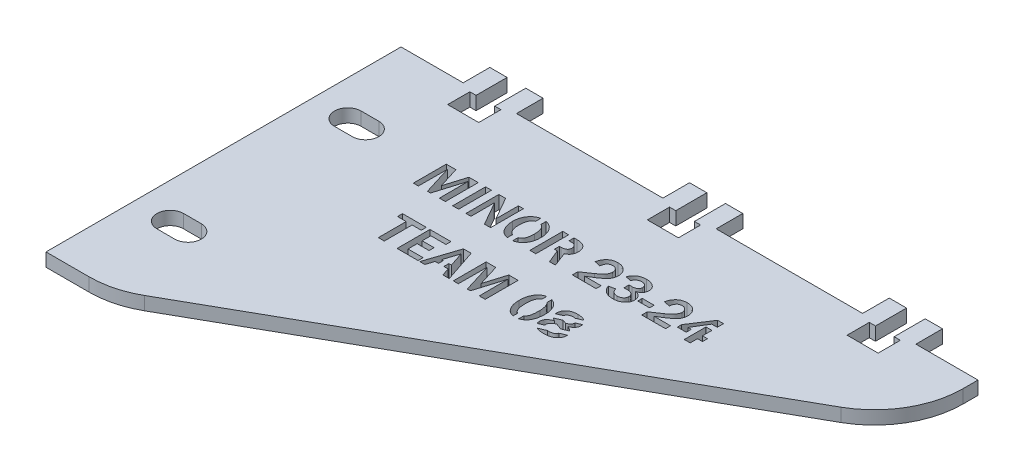
from build123d import *

# Parameters (mm, degrees)
SKETCH1_W               = 12
SKETCH1_H               = 6
BOSS_EXTRUDE1_DEPTH     = 3
CUT_EXTRUDE1_DEPTH      = 10
SKETCH3_W               = 4.2
SKETCH3_H               = 7
CUT_EXTRUDE2_DEPTH      = 10
FILLET1_R               = 20
SKETCH5_W               = 1.33798896
SKETCH5_H               = 7.41040039
SKETCH5_W_2             = 2.675977919
SKETCH5_H_2             = 1.029222276
CUT_EXTRUDE3_DEPTH      = 153.672852859
CUT_EXTRUDE3_DEPTH_BACK = 153.672852859
SKETCH6_W               = 1.2
SKETCH6_H               = 9.253585129
SKETCH6_H_2             = 4.425655788
SKETCH6_H_3             = 1.132144504
SKETCH6_H_4             = 1.586041103
SKETCH6_H_5             = 10.05312392
BOSS_EXTRUDE2_DEPTH     = 3


with BuildPart() as part:
    # Sketch1 → Boss-Extrude1 (new body)
    with BuildSketch(Plane(origin=(0, 0, 0), x_dir=(1, 0, 0), z_dir=(0, 1, 0))):
        Polygon((0, 0), (130, 0), (130, -15), (15, -80), (0, -80), align=None)
        with Locations((110, 3)):
            Rectangle(SKETCH1_W, SKETCH1_H)
        with Locations((65, 3)):
            Rectangle(SKETCH1_W, SKETCH1_H)
        with Locations((20, 3)):
            Rectangle(SKETCH1_W, SKETCH1_H)
    extrude(amount=BOSS_EXTRUDE1_DEPTH)

    # Sketch2 → Cut-Extrude1 (cut)
    with BuildSketch(Plane(origin=(0, 3, 0), x_dir=(1, 0, 0), z_dir=(0, 1, 0))):
        with BuildLine():
            Line((8, -17), (12, -17))
            ThreePointArc((12, -17), (15, -20), (12, -23))
            Line((12, -23), (8, -23))
            ThreePointArc((8, -23), (5, -20), (8, -17))
        make_face()
        with BuildLine():
            Line((8, -57), (12, -57))
            ThreePointArc((12, -57), (15, -60), (12, -63))
            Line((12, -63), (8, -63))
            ThreePointArc((8, -63), (5, -60), (8, -57))
        make_face()
    extrude(amount=-CUT_EXTRUDE1_DEPTH, mode=Mode.SUBTRACT)

    # Sketch3 → Cut-Extrude2 (cut)
    with BuildSketch(Plane(origin=(0, 3, 0), x_dir=(1, 0, 0), z_dir=(0, 1, 0))):
        Polygon((67.1, -1), (62.9, -1), (61.5, -1), (61.5, -6), (68.5, -6), (68.5, -1), align=None)
        with Locations((65, 2.5)):
            Rectangle(SKETCH3_W, SKETCH3_H)
        with Locations((20, 2.5)):
            Rectangle(SKETCH3_W, SKETCH3_H)
        Polygon((22.1, -1), (17.9, -1), (16.5, -1), (16.5, -6), (23.5, -6), (23.5, -1), align=None)
        with Locations((110, 2.5)):
            Rectangle(SKETCH3_W, SKETCH3_H)
        Polygon((112.1, -1), (107.9, -1), (106.5, -1), (106.5, -6), (113.5, -6), (113.5, -1), align=None)
    extrude(amount=-CUT_EXTRUDE2_DEPTH, mode=Mode.SUBTRACT)

    # Fillet1
    fillet1_edges = [part.edges().sort_by_distance(p)[0] for p in [
        (15, 1.5, 80),
        (130, 1.5, 15),
    ]]
    fillet(fillet1_edges, radius=FILLET1_R)

    # Sketch5 → Cut-Extrude3 (cut, two sides)
    with BuildSketch(Plane(origin=(0, 3, 0), x_dir=(1, 0, 0), z_dir=(0, 1, 0))) as cut_extrude3_sk:
        Polygon((35.169841553, -25.187136643), (33.831852594, -25.187136643), (33.806122037, -18.699819982), (31.834518113, -25.187136643), (31.134968597, -25.187136643), (29.123160679, -18.699819982), (29.097430122, -25.187136643), (27.965285618, -25.187136643), (27.965285618, -17.776736253), (30.134693197, -17.776736253), (31.619024699, -22.552970879), (33.071193005, -17.776736253), (35.169841553, -17.776736253), align=None)
        with Locations((37.485591675, -21.481936448)):
            Rectangle(SKETCH5_W, SKETCH5_H)
        with BuildLine():
            Line((45.35914209, -25.187136643), (43.982557295, -25.187136643))
            Line((43.982557295, -25.187136643), (41.282456979, -20.452714171))
            add(Edge.make_bspline(
                [(41.282456979, -20.452714171), (41.270682779, -20.431797346), (41.243481643, -20.383474624), (41.19764017, -20.30322362), (41.142168283, -20.204968249), (41.101838717, -20.134280536), (41.079828844, -20.095702694)],
                knots=[0, 0, 0, 0, 0.701659127, 1.620995457, 2.701657538, 4, 4, 4, 4], degree=3))
            add(Edge.make_bspline(
                [(41.079828844, -20.095702694), (41.057376283, -20.055999473), (41.009034469, -19.970515871), (40.959834914, -19.885522906), (40.933486301, -19.840005285)],
                knots=[0, 0, 0, 0, 0.928908489, 2, 2, 2, 2], degree=3))
            Line((40.933486301, -19.840005285), (40.933486301, -25.187136643))
            Line((40.933486301, -25.187136643), (39.801341797, -25.187136643))
            Line((39.801341797, -25.187136643), (39.801341797, -17.776736253))
            Line((39.801341797, -17.776736253), (41.333918093, -17.776736253))
            Line((41.333918093, -17.776736253), (43.832998433, -22.160579887))
            add(Edge.make_bspline(
                [(43.832998433, -22.160579887), (43.837248408, -22.168107128), (43.849182766, -22.189244387), (43.874094877, -22.229209862), (43.90650852, -22.288429086), (43.951390942, -22.365088204), (44.004747123, -22.460418787), (44.069890592, -22.573901828), (44.145183729, -22.70509438), (44.198619228, -22.799000771), (44.226997586, -22.848872284)],
                knots=[0, 0, 0, 0, 0.261565429, 0.734502253, 1.424635509, 2.303900059, 3.422602514, 4.730429657, 6.263606797, 8, 8, 8, 8], degree=3))
            Line((44.226997586, -22.848872284), (44.226997586, -17.776736253))
            Line((44.226997586, -17.776736253), (45.35914209, -17.776736253))
            Line((45.35914209, -17.776736253), (45.35914209, -25.187136643))
        make_face()
        with BuildLine():
            add(Edge.make_bspline(
                [(49.754242843, -25.290058871), (49.632891276, -25.286754572), (49.396021789, -25.280304821), (49.051602271, -25.227322774), (48.726768911, -25.143829664), (48.424603514, -25.019006097), (48.140378274, -24.865542033), (47.8799703, -24.672481692), (47.638344009, -24.44785055), (47.421371307, -24.188737197), (47.228750595, -23.90430109), (47.057006604, -23.60342544), (46.913441413, -23.28515113), (46.798250674, -22.950395916), (46.706123274, -22.600571487), (46.640242736, -22.233930005), (46.601437153, -21.851050748), (46.596644291, -21.590308792), (46.594208822, -21.457814051)],
                knots=[0, 0, 0, 0, 1.043242931, 2.036334791, 2.990296044, 3.920975987, 4.841273629, 5.761617468, 6.701129456, 7.67284199, 8.661396099, 9.652473746, 10.649166003, 11.659658399, 12.694112373, 13.757667053, 14.860569552, 16, 16, 16, 16], degree=3))
            add(Edge.make_bspline(
                [(46.594208822, -21.457814051), (46.597157529, -21.325845767), (46.602937091, -21.067183615), (46.643343111, -20.687402208), (46.711916991, -20.324079988), (46.810989894, -19.977545284), (46.93419259, -19.646584937), (47.086110352, -19.332389202), (47.26738475, -19.035767794), (47.473160389, -18.757250428), (47.701712451, -18.503605724), (47.950686317, -18.280910462), (48.218944515, -18.093907306), (48.504089865, -17.939443241), (48.807071544, -17.820004575), (49.127443147, -17.734440678), (49.465874986, -17.684317234), (49.697253933, -17.677363372), (49.815352915, -17.673814025)],
                knots=[0, 0, 0, 0, 1.138005514, 2.230528023, 3.28951566, 4.322679413, 5.335030664, 6.331615986, 7.327428993, 8.328774427, 9.313939261, 10.266815759, 11.203027922, 12.127628645, 13.057346614, 14.004915194, 14.981681401, 16, 16, 16, 16], degree=3))
            add(Edge.make_bspline(
                [(49.815352915, -17.673814025), (49.933980892, -17.677388737), (50.166412983, -17.684392798), (50.505501795, -17.734016488), (50.825222648, -17.820134617), (51.125941137, -17.938757069), (51.406804036, -18.093632022), (51.668837383, -18.281179871), (51.911440915, -18.503349786), (52.131796454, -18.757648206), (52.330410014, -19.03615612), (52.502414793, -19.335122742), (52.649708894, -19.649531655), (52.768879343, -19.98186353), (52.862246251, -20.330937375), (52.926996046, -20.697383405), (52.968879622, -21.079993866), (52.973188852, -21.340840845), (52.975386936, -21.473895649)],
                knots=[0, 0, 0, 0, 1.02633709, 2.010939425, 2.957178878, 3.885676847, 4.801130746, 5.725308908, 6.667572524, 7.640602601, 8.631640706, 9.622917575, 10.621029128, 11.631937575, 12.673784577, 13.743718798, 14.849098988, 16, 16, 16, 16], degree=3))
            add(Edge.make_bspline(
                [(52.975386936, -21.473895649), (52.972453465, -21.613360661), (52.966731853, -21.885381296), (52.92662653, -22.283417461), (52.857420932, -22.660872436), (52.761648266, -23.018407137), (52.637525753, -23.355809335), (52.483960681, -23.671310408), (52.305303264, -23.96812725), (52.098251049, -24.240397794), (51.869030567, -24.485897292), (51.621507833, -24.70223172), (51.355544848, -24.885465336), (51.068844984, -25.032157592), (50.76613176, -25.148862812), (50.4443628, -25.230265642), (50.105418989, -25.281778629), (49.872901792, -25.287261059), (49.754242843, -25.290058871)],
                knots=[0, 0, 0, 0, 1.192043689, 2.325031033, 3.415180851, 4.468890454, 5.485163586, 6.483175456, 7.463881689, 8.44170429, 9.401288739, 10.330189103, 11.246528187, 12.154384972, 13.076821252, 14.013677384, 14.986333232, 16, 16, 16, 16], degree=3))
        make_face()
        with BuildLine():
            add(Edge.make_bspline(
                [(49.768716281, -24.157914367), (49.829403619, -24.156035428), (49.948724584, -24.152341137), (50.123856515, -24.123840251), (50.292559302, -24.07945885), (50.453097156, -24.014006658), (50.608554569, -23.933674001), (50.753877226, -23.83123953), (50.893691587, -23.712714386), (51.026978001, -23.575660634), (51.149220558, -23.413345175), (51.253654299, -23.221521373), (51.339867183, -22.999519613), (51.411162249, -22.749079693), (51.46708555, -22.468880199), (51.506134733, -22.159886238), (51.530390948, -21.821110234), (51.533076436, -21.585438648), (51.534475749, -21.46263853)],
                knots=[0, 0, 0, 0, 0.799371324, 1.571691237, 2.33252148, 3.093351724, 3.851718398, 4.633574477, 5.430444829, 6.264760325, 7.147776758, 8.099444007, 9.133127046, 10.280064443, 11.526918667, 12.894681194, 14.381928343, 16, 16, 16, 16], degree=3))
            add(Edge.make_bspline(
                [(51.534475749, -21.46263853), (51.533257567, -21.361833849), (51.530883643, -21.16539144), (51.51202342, -20.87916303), (51.478043722, -20.609722716), (51.432139461, -20.357141991), (51.372436109, -20.121308276), (51.301166212, -19.901800399), (51.213530819, -19.69987664), (51.114552799, -19.514643758), (51.002234376, -19.346964978), (50.873609457, -19.201838681), (50.729689925, -19.078863974), (50.571455917, -18.978877447), (50.398145553, -18.900901159), (50.21077456, -18.844238461), (50.007802356, -18.812493864), (49.867994364, -18.808178853), (49.796054998, -18.805958529)],
                knots=[0, 0, 0, 0, 1.349221372, 2.629285592, 3.836961412, 4.98250601, 6.063184421, 7.091026383, 8.068024352, 9.005437678, 9.89898793, 10.762982643, 11.592597547, 12.424660018, 13.259563776, 14.128934283, 15.037227567, 16, 16, 16, 16], degree=3))
            add(Edge.make_bspline(
                [(49.796054998, -18.805958529), (49.724663117, -18.808298563), (49.586026627, -18.812842694), (49.384859433, -18.842857975), (49.198134614, -18.896615736), (49.024770679, -18.970424868), (48.865381069, -19.066593089), (48.719681717, -19.183627667), (48.586777602, -19.320648397), (48.470895466, -19.480846393), (48.367391009, -19.660831639), (48.278029965, -19.862002187), (48.2025388, -20.084466622), (48.140396693, -20.326928829), (48.092155333, -20.590775299), (48.059780776, -20.875547172), (48.038009526, -21.181408083), (48.036103518, -21.392374632), (48.035120009, -21.501234366)],
                knots=[0, 0, 0, 0, 0.939796333, 1.824998347, 2.669230575, 3.491078229, 4.298254311, 5.111545101, 5.944944068, 6.80304059, 7.707165261, 8.673682073, 9.695711643, 10.796188878, 11.965695931, 13.223433485, 14.567278583, 16, 16, 16, 16], degree=3))
            add(Edge.make_bspline(
                [(48.035120009, -21.501234366), (48.036161849, -21.606873188), (48.038184278, -21.811940116), (48.059235339, -22.109375305), (48.09412667, -22.387614942), (48.143809831, -22.645934818), (48.205512725, -22.885075408), (48.28316845, -23.104042709), (48.374314804, -23.30337453), (48.478565131, -23.483806791), (48.598232373, -23.64179017), (48.728955951, -23.779834985), (48.871700289, -23.897250747), (49.027534115, -23.993018394), (49.19594962, -24.066992868), (49.376210512, -24.120855387), (49.568836956, -24.15090012), (49.70107372, -24.155540626), (49.768716281, -24.157914367)],
                knots=[0, 0, 0, 0, 1.41748779, 2.751638642, 3.999067725, 5.17855805, 6.279598804, 7.310334916, 8.292109387, 9.21746807, 10.100882045, 10.945543608, 11.763498334, 12.574112435, 13.392193692, 14.225256955, 15.09217254, 16, 16, 16, 16], degree=3))
        make_face(mode=Mode.SUBTRACT)
        with BuildLine():
            Line((59.974098416, -25.187136643), (58.636109457, -25.187136643))
            Line((58.636109457, -25.187136643), (57.401042725, -22.202392041))
            Line((57.401042725, -22.202392041), (55.548442627, -22.202392041))
            Line((55.548442627, -22.202392041), (55.548442627, -25.187136643))
            Line((55.548442627, -25.187136643), (54.210453668, -25.187136643))
            Line((54.210453668, -25.187136643), (54.210453668, -17.776736253))
            Line((54.210453668, -17.776736253), (57.396218245, -17.776736253))
            add(Edge.make_bspline(
                [(57.396218245, -17.776736253), (57.503496708, -17.778458656), (57.710965158, -17.781789653), (58.011465976, -17.810999855), (58.289400583, -17.858736399), (58.546274192, -17.923727134), (58.7806213, -18.010943687), (58.993431572, -18.116550053), (59.184953026, -18.241334202), (59.351861155, -18.387008185), (59.498317615, -18.547113553), (59.626733884, -18.717760647), (59.732669371, -18.901567644), (59.822554267, -19.094695603), (59.889049965, -19.300849715), (59.93980226, -19.516846147), (59.968697019, -19.744876374), (59.972273402, -19.900500689), (59.974098416, -19.979915188)],
                knots=[0, 0, 0, 0, 1.335720457, 2.583182541, 3.755296818, 4.844974608, 5.877881988, 6.863070127, 7.798083025, 8.716214529, 9.613877828, 10.496396048, 11.369981769, 12.251186115, 13.14414573, 14.062301502, 15.011199793, 16, 16, 16, 16], degree=3))
            add(Edge.make_bspline(
                [(59.974098416, -19.979915188), (59.97320722, -20.038912106), (59.971454465, -20.154943944), (59.956583615, -20.325717751), (59.932898952, -20.48960581), (59.898979466, -20.64649505), (59.8555602, -20.796456343), (59.802737194, -20.939597408), (59.740053893, -21.075277141), (59.666519619, -21.203235558), (59.585250693, -21.325421296), (59.493182208, -21.440009138), (59.391042985, -21.546570655), (59.279670568, -21.646414992), (59.159166987, -21.740058965), (59.02790569, -21.825038106), (58.887907966, -21.904425156), (58.789218193, -21.95056828), (58.739031684, -21.974033349)],
                knots=[0, 0, 0, 0, 1.131954292, 2.226264395, 3.286789501, 4.307712215, 5.303873972, 6.28029505, 7.232964977, 8.168203638, 9.109700785, 10.046296176, 10.984866615, 11.939090291, 12.914372813, 13.910109586, 14.937232292, 16, 16, 16, 16], degree=3))
            Line((58.739031684, -21.974033349), (59.974098416, -25.187136643))
        make_face()
        with BuildLine():
            Line((55.548442627, -21.070247537), (57.153386115, -21.070247537))
            add(Edge.make_bspline(
                [(57.153386115, -21.070247537), (57.209685416, -21.069172783), (57.318684017, -21.067091999), (57.476889538, -21.055349311), (57.623908775, -21.030348554), (57.759979977, -20.998817752), (57.885776208, -20.959525789), (57.998469594, -20.906634316), (58.102351284, -20.848582171), (58.192980039, -20.777795622), (58.273477224, -20.70091853), (58.343875261, -20.616642802), (58.401315011, -20.524021598), (58.450368891, -20.425829431), (58.486856768, -20.32021046), (58.514760113, -20.208416525), (58.530866925, -20.089206067), (58.53240245, -20.007301621), (58.533187229, -19.96544175)],
                knots=[0, 0, 0, 0, 1.344229283, 2.602503167, 3.782741052, 4.900187672, 5.936188447, 6.921138906, 7.867162451, 8.770685931, 9.657654768, 10.521141536, 11.383869362, 12.25378041, 13.136121391, 14.045516368, 15.001098993, 16, 16, 16, 16], degree=3))
            add(Edge.make_bspline(
                [(58.533187229, -19.96544175), (58.532478978, -19.926775961), (58.531095215, -19.851231721), (58.513848318, -19.740952028), (58.488989094, -19.636039788), (58.451785822, -19.537105811), (58.402658634, -19.444879435), (58.344397844, -19.357691919), (58.276924551, -19.274837963), (58.197380813, -19.199626997), (58.10959699, -19.130441592), (58.012440943, -19.070574087), (57.906868769, -19.021230357), (57.793992825, -18.977904784), (57.670815257, -18.949618777), (57.540825559, -18.923737459), (57.401784388, -18.912124727), (57.306708106, -18.909980923), (57.257916502, -18.908880757)],
                knots=[0, 0, 0, 0, 0.992824672, 1.939755693, 2.862010381, 3.760178974, 4.64761104, 5.541755275, 6.451994452, 7.387429984, 8.349277355, 9.320453258, 10.312608556, 11.341393932, 12.420692153, 13.555625423, 14.745586657, 16, 16, 16, 16], degree=3))
            Line((57.257916502, -18.908880757), (55.548442627, -18.908880757))
            Line((55.548442627, -18.908880757), (55.548442627, -21.070247537))
        make_face(mode=Mode.SUBTRACT)
        with BuildLine():
            Line((69.134176677, -24.054992139), (69.134176677, -25.187136643))
            Line((69.134176677, -25.187136643), (63.782220839, -25.187136643))
            Line((63.782220839, -25.187136643), (63.782220839, -23.952069911))
            Line((63.782220839, -23.952069911), (66.040077208, -22.416277296))
            add(Edge.make_bspline(
                [(66.040077208, -22.416277296), (66.124598129, -22.357816395), (66.288217544, -22.244645145), (66.519098898, -22.072679496), (66.729782167, -21.907054924), (66.917225684, -21.745137893), (67.083918789, -21.588817257), (67.22929058, -21.438263298), (67.35241801, -21.291563067), (67.484152573, -21.107336044), (67.612858667, -20.8834899), (67.72964333, -20.623067195), (67.802805509, -20.371429424), (67.81244531, -20.206020761), (67.817093795, -20.126257731)],
                knots=[0, 0, 0, 0, 1.229862298, 2.380822965, 3.444895239, 4.436507299, 5.34421092, 6.17911993, 6.939761485, 7.63409447, 8.887427135, 10.022181352, 11.046260297, 12, 12, 12, 12], degree=3))
            add(Edge.make_bspline(
                [(67.817093795, -20.126257731), (67.81649038, -20.080622689), (67.815299998, -19.990596546), (67.796231492, -19.858952089), (67.769462705, -19.732302648), (67.730934066, -19.611499609), (67.680446516, -19.49639809), (67.619509969, -19.386749608), (67.546221021, -19.283158394), (67.463049905, -19.186026638), (67.372560698, -19.096059768), (67.273923686, -19.018164084), (67.167591474, -18.953472557), (67.055913379, -18.898786872), (66.936830124, -18.856081562), (66.811405139, -18.828246214), (66.679601004, -18.809660441), (66.589598622, -18.807213636), (66.543431228, -18.805958529)],
                knots=[0, 0, 0, 0, 1.065512965, 2.101981715, 3.102077151, 4.088584561, 5.059133596, 6.035004281, 7.015127496, 8.019294744, 9.020331299, 9.992738154, 10.948869268, 11.923774542, 12.894566102, 13.897404, 14.921457678, 16, 16, 16, 16], degree=3))
            add(Edge.make_bspline(
                [(66.543431228, -18.805958529), (66.492992902, -18.807260093), (66.395011275, -18.809788516), (66.2516817, -18.827543226), (66.117136522, -18.858044709), (65.990064177, -18.899599083), (65.872385056, -18.954996479), (65.761731956, -19.020909301), (65.660443709, -19.100553834), (65.566022087, -19.191085974), (65.481285463, -19.294805295), (65.402905318, -19.409261148), (65.336704652, -19.53772014), (65.274263875, -19.676001334), (65.224001109, -19.827800586), (65.180358738, -19.990999992), (65.145061988, -20.166132938), (65.128638634, -20.287502398), (65.120209798, -20.349791944)],
                knots=[0, 0, 0, 0, 1.033864903, 2.008388711, 2.954750571, 3.858226192, 4.743134108, 5.61567469, 6.492701372, 7.378632106, 8.291745958, 9.233503247, 10.216662244, 11.249826143, 12.340968833, 13.489791962, 14.711704583, 16, 16, 16, 16], degree=3))
            Line((65.120209798, -20.349791944), (63.782220839, -20.041025261))
            add(Edge.make_bspline(
                [(63.782220839, -20.041025261), (63.795914532, -19.960876274), (63.823083313, -19.801857786), (63.886630425, -19.570111601), (63.966877098, -19.347267436), (64.065857674, -19.133944211), (64.181773586, -18.928486081), (64.317375331, -18.732910433), (64.469528304, -18.544831365), (64.638451692, -18.367273797), (64.824251537, -18.205106917), (65.024925403, -18.062405125), (65.239354872, -17.941520008), (65.467800112, -17.842574333), (65.710650813, -17.767453893), (65.966766291, -17.712760938), (66.23705046, -17.680338081), (66.42165849, -17.67602191), (66.516092511, -17.673814025)],
                knots=[0, 0, 0, 0, 0.98359574, 1.951489518, 2.903753932, 3.847159055, 4.794304505, 5.755280849, 6.723935353, 7.719694664, 8.717565248, 9.704045282, 10.69465545, 11.691365387, 12.711181735, 13.76605545, 14.857252499, 16, 16, 16, 16], degree=3))
            add(Edge.make_bspline(
                [(66.516092511, -17.673814025), (66.61374329, -17.676017415), (66.804765148, -17.680327628), (67.084081302, -17.712805315), (67.348629137, -17.766742475), (67.597279172, -17.844402027), (67.831074546, -17.942534264), (68.048802917, -18.064237412), (68.253127804, -18.205638329), (68.438407778, -18.37043739), (68.607344726, -18.549459996), (68.754483443, -18.742747523), (68.876945663, -18.94898339), (68.979562677, -19.16554152), (69.058162445, -19.39490356), (69.114245258, -19.635722793), (69.148995202, -19.888308963), (69.153025403, -20.060745782), (69.155082754, -20.148771968)],
                knots=[0, 0, 0, 0, 1.152255969, 2.25401251, 3.313604111, 4.334097601, 5.32346634, 6.300480333, 7.272771944, 8.24999074, 9.221232104, 10.174001265, 11.110329718, 12.047085523, 12.997415133, 13.965705612, 14.96152586, 16, 16, 16, 16], degree=3))
            add(Edge.make_bspline(
                [(69.155082754, -20.148771968), (69.153219451, -20.227114465), (69.149530934, -20.382198042), (69.120355283, -20.611734802), (69.069408291, -20.834001601), (69.002885255, -21.051165724), (68.912394041, -21.260399121), (68.807545855, -21.465762922), (68.678704137, -21.66216774), (68.556304966, -21.821459064), (68.44386031, -21.94931702), (68.343127138, -22.050367487), (68.229371553, -22.158175401), (68.099838727, -22.270414903), (67.957186346, -22.389545208), (67.799459952, -22.512629752), (67.62817993, -22.642221318), (67.441613642, -22.776598297), (67.241018691, -22.918223829), (67.025459866, -23.06454558), (66.795104914, -23.214863226), (66.552370478, -23.373770734), (66.293003977, -23.535206904), (66.020416759, -23.703960339), (65.733145893, -23.878295136), (65.536288363, -23.995123619), (65.435409121, -24.054992139)],
                knots=[0, 0, 0, 0, 0.995890277, 1.971423344, 2.935388841, 3.89246317, 4.854499288, 5.829960929, 6.820543246, 7.836131339, 8.381747654, 8.984170071, 9.649502455, 10.373990851, 11.162843686, 12.012258602, 12.917349624, 13.893453902, 14.935320887, 16.039270622, 17.205582843, 18.432451933, 19.72777502, 21.089579236, 22.508560772, 24, 24, 24, 24], degree=3))
            Line((65.435409121, -24.054992139), (69.134176677, -24.054992139))
        make_face()
        with BuildLine():
            Line((72.118921278, -21.893625359), (72.118921278, -20.761480854))
            Line((72.118921278, -20.761480854), (72.783091279, -20.761480854))
            add(Edge.make_bspline(
                [(72.783091279, -20.761480854), (72.8787699, -20.758876823), (73.062967215, -20.753863629), (73.326277201, -20.702068072), (73.566184077, -20.622696055), (73.746018015, -20.527228991), (73.872247226, -20.434216086), (73.955100879, -20.35755477), (74.023673712, -20.270299416), (74.079453016, -20.175997223), (74.123772061, -20.07393562), (74.156379319, -19.964517218), (74.173372803, -19.845896269), (74.176010066, -19.764469518), (74.177365831, -19.722609619)],
                knots=[0, 0, 0, 0, 1.757519155, 3.383517712, 4.914201172, 6.391774362, 7.10354432, 7.793967393, 8.460615103, 9.136887641, 9.803535351, 10.502283397, 11.230053218, 12, 12, 12, 12], degree=3))
            add(Edge.make_bspline(
                [(74.177365831, -19.722609619), (74.1766419, -19.68127737), (74.175244369, -19.601486586), (74.158718042, -19.485539297), (74.131327081, -19.377870925), (74.094672285, -19.27705868), (74.046087872, -19.184476853), (73.985942236, -19.100701414), (73.916350099, -19.023843056), (73.807386912, -18.934110586), (73.652612186, -18.838522595), (73.440873871, -18.760729045), (73.206195166, -18.710972634), (73.041206505, -18.705756521), (72.955164378, -18.703036301)],
                knots=[0, 0, 0, 0, 0.82531779, 1.593253586, 2.333581598, 3.041838554, 3.731717398, 4.415248554, 5.097519899, 5.796894261, 7.229672891, 8.707614889, 10.283010373, 12, 12, 12, 12], degree=3))
            add(Edge.make_bspline(
                [(72.955164378, -18.703036301), (72.868087854, -18.705908132), (72.699470409, -18.711469227), (72.45748826, -18.760396961), (72.23688348, -18.841180939), (72.037878705, -18.954762082), (71.861781024, -19.102433903), (71.707848329, -19.281690748), (71.576106788, -19.493553364), (71.509940101, -19.650790022), (71.475657356, -19.732258578)],
                knots=[0, 0, 0, 0, 1.07961905, 2.090604884, 3.048189036, 3.983781537, 4.918901014, 5.885681864, 6.904514715, 8, 8, 8, 8], degree=3))
            Line((71.475657356, -19.732258578), (70.240590624, -19.526414123))
            add(Edge.make_bspline(
                [(70.240590624, -19.526414123), (70.259032718, -19.459479038), (70.295629974, -19.326650277), (70.374906308, -19.136322557), (70.467520551, -18.953623317), (70.578867345, -18.781427256), (70.707401597, -18.619675857), (70.851267667, -18.466103881), (71.011973065, -18.321026674), (71.190304532, -18.188601752), (71.381341993, -18.068545776), (71.582156328, -17.961317808), (71.794448809, -17.873695979), (72.014295716, -17.798879191), (72.244717768, -17.742732139), (72.483935562, -17.703102658), (72.73324673, -17.678154833), (72.902571391, -17.675280224), (72.988935734, -17.673814025)],
                knots=[0, 0, 0, 0, 0.931108376, 1.847730124, 2.761664946, 3.677778197, 4.594767017, 5.531447042, 6.49949516, 7.496784875, 8.508915719, 9.52602184, 10.548332271, 11.58819233, 12.640524623, 13.727632304, 14.840974838, 16, 16, 16, 16], degree=3))
            add(Edge.make_bspline(
                [(72.988935734, -17.673814025), (73.074781421, -17.675115411), (73.243657804, -17.677675508), (73.491178296, -17.705036368), (73.729563351, -17.744227939), (73.95835246, -17.801946674), (74.177068903, -17.878514947), (74.387744715, -17.967832241), (74.58728848, -18.076607522), (74.776428782, -18.199092959), (74.948870303, -18.335762226), (75.100915613, -18.484842758), (75.228527286, -18.646666217), (75.333898941, -18.819204215), (75.415493789, -19.00362725), (75.472567158, -19.198851545), (75.509835447, -19.405460644), (75.513486025, -19.547153485), (75.515354791, -19.619687391)],
                knots=[0, 0, 0, 0, 1.157267141, 2.276585997, 3.354565457, 4.413615651, 5.453869431, 6.477179381, 7.496113183, 8.514739181, 9.51281408, 10.458538842, 11.379853686, 12.284943352, 13.178263199, 14.090914698, 15.02272116, 16, 16, 16, 16], degree=3))
            add(Edge.make_bspline(
                [(75.515354791, -19.619687391), (75.514220342, -19.673900812), (75.511988926, -19.780536403), (75.491376587, -19.936847155), (75.462344636, -20.087611876), (75.415542864, -20.231075821), (75.360530952, -20.370496435), (75.288584502, -20.502028199), (75.206141675, -20.628679646), (75.112019394, -20.748228984), (75.008687426, -20.857991138), (74.898356949, -20.956254556), (74.780719395, -21.039252089), (74.658501189, -21.11085503), (74.529519127, -21.167880046), (74.39460231, -21.210652139), (74.253606827, -21.242210354), (74.157143649, -21.251886219), (74.10821496, -21.256794075)],
                knots=[0, 0, 0, 0, 1.092862439, 2.149615931, 3.175896718, 4.184657502, 5.188539406, 6.194689447, 7.202290735, 8.234024458, 9.258937478, 10.239432411, 11.208474603, 12.157957866, 13.09217493, 14.046141402, 15.008950968, 16, 16, 16, 16], degree=3))
            add(Edge.make_bspline(
                [(74.10821496, -21.256794075), (74.167362944, -21.267181963), (74.28390677, -21.287650017), (74.453442951, -21.332977358), (74.614601495, -21.390429111), (74.765994671, -21.461753651), (74.908684803, -21.543672681), (75.041400332, -21.639501055), (75.165005462, -21.747840461), (75.280926122, -21.865585822), (75.382712338, -21.99441329), (75.474095936, -22.128723287), (75.551852839, -22.269848901), (75.612166743, -22.418860111), (75.661316215, -22.573039782), (75.696321366, -22.733414424), (75.718090547, -22.900803866), (75.720149227, -23.014444605), (75.721199246, -23.072406497)],
                knots=[0, 0, 0, 0, 1.082628236, 2.133185734, 3.160671011, 4.164041765, 5.147324725, 6.123931584, 7.110677738, 8.108818675, 9.099251846, 10.067207489, 11.03627287, 11.998563517, 12.961679352, 13.951546182, 14.955196336, 16, 16, 16, 16], degree=3))
            add(Edge.make_bspline(
                [(75.721199246, -23.072406497), (75.719406727, -23.151370896), (75.715874101, -23.306990856), (75.67686728, -23.534364456), (75.618140704, -23.751566514), (75.533926499, -23.957443392), (75.424515763, -24.151306511), (75.294201814, -24.336680938), (75.136020838, -24.508205822), (74.958835156, -24.670358093), (74.760751827, -24.816772118), (74.545126773, -24.94391787), (74.313226557, -25.049420691), (74.067600226, -25.139698848), (73.804684769, -25.205165747), (73.527175318, -25.256066967), (73.233442313, -25.284688312), (73.032415055, -25.288239623), (72.929433821, -25.290058871)],
                knots=[0, 0, 0, 0, 0.947996689, 1.868274918, 2.763758024, 3.647768475, 4.533092253, 5.433934539, 6.364258009, 7.330978942, 8.316573627, 9.318598283, 10.333133814, 11.374393466, 12.458679656, 13.584496418, 14.762597957, 16, 16, 16, 16], degree=3))
            add(Edge.make_bspline(
                [(72.929433821, -25.290058871), (72.833955841, -25.28812515), (72.646888244, -25.28433646), (72.372619046, -25.257023798), (72.111478322, -25.21015495), (71.862604095, -25.146470276), (71.626439556, -25.062222985), (71.402913334, -24.959713556), (71.192412341, -24.837808055), (70.995544018, -24.70049471), (70.815745446, -24.549323692), (70.650304531, -24.393482195), (70.503814025, -24.230776068), (70.374337248, -24.062461094), (70.260918568, -23.889524621), (70.168272155, -23.709339241), (70.088390073, -23.525956579), (70.05261184, -23.398287448), (70.034746169, -23.334536546)],
                knots=[0, 0, 0, 0, 1.21949585, 2.389327443, 3.516208705, 4.605668683, 5.666876008, 6.714678352, 7.742330507, 8.769982662, 9.776429577, 10.740233872, 11.671102128, 12.569523065, 13.450767421, 14.308310604, 15.155263882, 16, 16, 16, 16], degree=3))
            Line((70.034746169, -23.334536546), (71.372735128, -23.025769863))
            add(Edge.make_bspline(
                [(71.372735128, -23.025769863), (71.388719865, -23.075844529), (71.419995643, -23.173820748), (71.47660628, -23.313978634), (71.539287894, -23.444603519), (71.608259411, -23.566145243), (71.685688411, -23.677219128), (71.769627433, -23.778286161), (71.858279117, -23.872141982), (71.956687629, -23.952840149), (72.059991367, -24.026164357), (72.170241115, -24.089500199), (72.287435848, -24.141860288), (72.410941011, -24.186088078), (72.541284974, -24.219432914), (72.678902234, -24.243546845), (72.822979748, -24.25812398), (72.921359339, -24.25992389), (72.971245976, -24.260836594)],
                knots=[0, 0, 0, 0, 1.150338954, 2.250756138, 3.305685926, 4.320159362, 5.306484759, 6.265056662, 7.194528831, 8.127549744, 9.045618743, 9.965485823, 10.905564039, 11.851992481, 12.833910401, 13.846753723, 14.908124997, 16, 16, 16, 16], degree=3))
            add(Edge.make_bspline(
                [(72.971245976, -24.260836594), (73.022745244, -24.260038264), (73.123864446, -24.258470736), (73.271341771, -24.242454023), (73.410967326, -24.214556173), (73.542894527, -24.177974793), (73.667929183, -24.1310498), (73.785496701, -24.073906918), (73.89377602, -24.003212728), (73.994990967, -23.925290373), (74.085280979, -23.838986183), (74.166234155, -23.748721066), (74.230887261, -23.650952868), (74.288806159, -23.552341492), (74.330632179, -23.446918904), (74.361317086, -23.338130937), (74.379241301, -23.224157955), (74.381873576, -23.146978811), (74.383210287, -23.107786013)],
                knots=[0, 0, 0, 0, 1.214856538, 2.385380037, 3.494206912, 4.571417582, 5.612142953, 6.641662861, 7.648636091, 8.65814818, 9.651283319, 10.592477144, 11.511655716, 12.412195603, 13.285955333, 14.179002484, 15.075268477, 16, 16, 16, 16], degree=3))
            add(Edge.make_bspline(
                [(74.383210287, -23.107786013), (74.379486799, -23.02905148), (74.372137818, -22.873654543), (74.304466212, -22.649600322), (74.196124644, -22.441187431), (74.071966752, -22.284568446), (73.953717638, -22.170945663), (73.851303589, -22.096691457), (73.73787481, -22.033683995), (73.613587952, -21.982550191), (73.478923174, -21.942268202), (73.333630108, -21.913144171), (73.17741045, -21.897995921), (73.069908225, -21.895108904), (73.014666291, -21.893625359)],
                knots=[0, 0, 0, 0, 1.373789541, 2.711423793, 4.052861503, 5.461005822, 6.18365657, 6.914766728, 7.665790807, 8.447308189, 9.259742248, 10.119966547, 11.033911314, 12, 12, 12, 12], degree=3))
            Line((73.014666291, -21.893625359), (72.118921278, -21.893625359))
        make_face()
        with Locations((77.573799344, -22.408236497)):
            Rectangle(SKETCH5_W_2, SKETCH5_H_2)
        with BuildLine():
            Line((84.778355279, -24.054992139), (84.778355279, -25.187136643))
            Line((84.778355279, -25.187136643), (79.426399441, -25.187136643))
            Line((79.426399441, -25.187136643), (79.426399441, -23.952069911))
            Line((79.426399441, -23.952069911), (81.68425581, -22.416277296))
            add(Edge.make_bspline(
                [(81.68425581, -22.416277296), (81.768776732, -22.357816395), (81.932396147, -22.244645145), (82.1632775, -22.072679496), (82.373960769, -21.907054924), (82.561404286, -21.745137893), (82.728097392, -21.588817257), (82.873469183, -21.438263298), (82.996596612, -21.291563067), (83.128331176, -21.107336044), (83.257037269, -20.8834899), (83.373821932, -20.623067195), (83.446984112, -20.371429424), (83.456623912, -20.206020761), (83.461272397, -20.126257731)],
                knots=[0, 0, 0, 0, 1.229862298, 2.380822965, 3.444895239, 4.436507299, 5.34421092, 6.17911993, 6.939761485, 7.63409447, 8.887427135, 10.022181352, 11.046260297, 12, 12, 12, 12], degree=3))
            add(Edge.make_bspline(
                [(83.461272397, -20.126257731), (83.460668982, -20.080622689), (83.459478601, -19.990596546), (83.440410094, -19.858952089), (83.413641308, -19.732302648), (83.375112668, -19.611499609), (83.324625118, -19.49639809), (83.263688572, -19.386749608), (83.190399624, -19.283158394), (83.107228507, -19.186026638), (83.0167393, -19.096059768), (82.918102288, -19.018164084), (82.811770076, -18.953472557), (82.700091982, -18.898786872), (82.581008727, -18.856081562), (82.455583741, -18.828246214), (82.323779606, -18.809660441), (82.233777224, -18.807213636), (82.18760983, -18.805958529)],
                knots=[0, 0, 0, 0, 1.065512965, 2.101981715, 3.102077151, 4.088584561, 5.059133596, 6.035004281, 7.015127496, 8.019294744, 9.020331299, 9.992738154, 10.948869268, 11.923774542, 12.894566102, 13.897404, 14.921457678, 16, 16, 16, 16], degree=3))
            add(Edge.make_bspline(
                [(82.18760983, -18.805958529), (82.137171504, -18.807260093), (82.039189878, -18.809788516), (81.895860302, -18.827543226), (81.761315125, -18.858044709), (81.634242779, -18.899599083), (81.516563658, -18.954996479), (81.405910558, -19.020909301), (81.304622311, -19.100553834), (81.21020069, -19.191085974), (81.125464066, -19.294805295), (81.04708392, -19.409261148), (80.980883254, -19.53772014), (80.918442477, -19.676001334), (80.868179711, -19.827800586), (80.82453734, -19.990999992), (80.789240591, -20.166132938), (80.772817237, -20.287502398), (80.764388401, -20.349791944)],
                knots=[0, 0, 0, 0, 1.033864903, 2.008388711, 2.954750571, 3.858226192, 4.743134108, 5.61567469, 6.492701372, 7.378632106, 8.291745958, 9.233503247, 10.216662244, 11.249826143, 12.340968833, 13.489791962, 14.711704583, 16, 16, 16, 16], degree=3))
            Line((80.764388401, -20.349791944), (79.426399441, -20.041025261))
            add(Edge.make_bspline(
                [(79.426399441, -20.041025261), (79.440093134, -19.960876274), (79.467261916, -19.801857786), (79.530809028, -19.570111601), (79.6110557, -19.347267436), (79.710036277, -19.133944211), (79.825952189, -18.928486081), (79.961553934, -18.732910433), (80.113706906, -18.544831365), (80.282630294, -18.367273797), (80.46843014, -18.205106917), (80.669104005, -18.062405125), (80.883533475, -17.941520008), (81.111978714, -17.842574333), (81.354829415, -17.767453893), (81.610944893, -17.712760938), (81.881229062, -17.680338081), (82.065837093, -17.67602191), (82.160271113, -17.673814025)],
                knots=[0, 0, 0, 0, 0.98359574, 1.951489518, 2.903753932, 3.847159055, 4.794304505, 5.755280849, 6.723935353, 7.719694664, 8.717565248, 9.704045282, 10.69465545, 11.691365387, 12.711181735, 13.76605545, 14.857252499, 16, 16, 16, 16], degree=3))
            add(Edge.make_bspline(
                [(82.160271113, -17.673814025), (82.257921892, -17.676017415), (82.44894375, -17.680327628), (82.728259904, -17.712805315), (82.992807739, -17.766742475), (83.241457775, -17.844402027), (83.475253149, -17.942534264), (83.692981519, -18.064237412), (83.897306406, -18.205638329), (84.08258638, -18.37043739), (84.251523329, -18.549459996), (84.398662046, -18.742747523), (84.521124265, -18.94898339), (84.623741279, -19.16554152), (84.702341048, -19.39490356), (84.75842386, -19.635722793), (84.793173805, -19.888308963), (84.797204005, -20.060745782), (84.799261357, -20.148771968)],
                knots=[0, 0, 0, 0, 1.152255969, 2.25401251, 3.313604111, 4.334097601, 5.32346634, 6.300480333, 7.272771944, 8.24999074, 9.221232104, 10.174001265, 11.110329718, 12.047085523, 12.997415133, 13.965705612, 14.96152586, 16, 16, 16, 16], degree=3))
            add(Edge.make_bspline(
                [(84.799261357, -20.148771968), (84.797398054, -20.227114465), (84.793709537, -20.382198042), (84.764533886, -20.611734802), (84.713586894, -20.834001601), (84.647063857, -21.051165724), (84.556572644, -21.260399121), (84.451724458, -21.465762922), (84.32288274, -21.66216774), (84.200483568, -21.821459064), (84.088038913, -21.94931702), (83.98730574, -22.050367487), (83.873550156, -22.158175401), (83.744017329, -22.270414903), (83.601364949, -22.389545208), (83.443638555, -22.512629752), (83.272358532, -22.642221318), (83.085792245, -22.776598297), (82.885197293, -22.918223829), (82.669638469, -23.06454558), (82.439283516, -23.214863226), (82.196549081, -23.373770734), (81.93718258, -23.535206904), (81.664595361, -23.703960339), (81.377324495, -23.878295136), (81.180466966, -23.995123619), (81.079587723, -24.054992139)],
                knots=[0, 0, 0, 0, 0.995890277, 1.971423344, 2.935388841, 3.89246317, 4.854499288, 5.829960929, 6.820543246, 7.836131339, 8.381747654, 8.984170071, 9.649502455, 10.373990851, 11.162843686, 12.012258602, 12.917349624, 13.893453902, 14.935320887, 16.039270622, 17.205582843, 18.432451933, 19.72777502, 21.089579236, 22.508560772, 24, 24, 24, 24], degree=3))
            Line((81.079587723, -24.054992139), (84.778355279, -24.054992139))
        make_face()
        Polygon((90.336155572, -25.187136643), (88.998166613, -25.187136643), (88.998166613, -23.540381001), (85.807577556, -23.540381001), (85.807577556, -22.570660637), (88.998166613, -17.673814025), (90.336155572, -17.673814025), (90.336155572, -22.408236497), (91.468300076, -22.408236497), (91.468300076, -23.540381001), (90.336155572, -23.540381001), align=None)
        with BuildLine():
            Line((89.096264361, -19.088994655), (87.076415643, -22.408236497))
            Line((87.076415643, -22.408236497), (88.998166613, -22.408236497))
            Line((88.998166613, -22.408236497), (88.998166613, -20.377130661))
            add(Edge.make_bspline(
                [(88.998166613, -20.377130661), (88.999195587, -20.274650536), (89.001149009, -20.080100418), (89.020956161, -19.886566087), (89.030329809, -19.79497681)],
                knots=[0, 0, 0, 0, 1.053508737, 2, 2, 2, 2], degree=3))
            Line((89.030329809, -19.79497681), (89.096264361, -19.088994655))
        make_face(mode=Mode.SUBTRACT)
        Polygon((35.993219374, -39.772870693), (34.655230415, -39.772870693), (34.655230415, -33.494614806), (32.699708089, -33.494614806), (32.699708089, -32.362470302), (38.051663927, -32.362470302), (38.051663927, -33.494614806), (35.993219374, -33.494614806), align=None)
        Polygon((43.60946422, -39.772870693), (38.875041748, -39.772870693), (38.875041748, -32.362470302), (43.60946422, -32.362470302), (43.60946422, -33.494614806), (40.213030708, -33.494614806), (40.213030708, -35.450137132), (42.889008627, -35.450137132), (42.889008627, -36.582281636), (40.213030708, -36.582281636), (40.213030708, -38.640726189), (43.60946422, -38.640726189), align=None)
        Polygon((50.633906257, -39.772870693), (49.207468508, -39.772870693), (48.625314658, -38.023192823), (45.712937248, -38.023192823), (45.135607877, -39.772870693), (43.995422574, -39.772870693), (46.438217321, -32.362470302), (48.163772793, -32.362470302), align=None)
        Polygon((48.245788944, -36.891048319), (47.160281074, -33.63291655), (46.084422163, -36.891048319), align=None, mode=Mode.SUBTRACT)
        Polygon((58.739031684, -39.772870693), (57.401042725, -39.772870693), (57.375312168, -33.285554031), (55.403708245, -39.772870693), (54.704158729, -39.772870693), (52.69235081, -33.285554031), (52.666620253, -39.772870693), (51.534475749, -39.772870693), (51.534475749, -32.362470302), (53.703883329, -32.362470302), (55.18821483, -37.138704929), (56.640383136, -32.362470302), (58.739031684, -32.362470302), align=None)
        with BuildLine():
            add(Edge.make_bspline(
                [(65.562453745, -39.87579292), (65.452880108, -39.873076459), (65.239497647, -39.867786454), (64.929406915, -39.815777356), (64.637709935, -39.735049054), (64.366391186, -39.61802129), (64.11305462, -39.470363938), (63.880963268, -39.287428353), (63.669127017, -39.070651165), (63.47676845, -38.825142545), (63.307864208, -38.55248118), (63.158077416, -38.261875653), (63.031619858, -37.952603762), (62.931894139, -37.625303192), (62.850568179, -37.281151961), (62.793236311, -36.918909696), (62.759212507, -36.538448347), (62.75509868, -36.278946542), (62.752998563, -36.146470328)],
                knots=[0, 0, 0, 0, 1.001184976, 1.949696286, 2.866767837, 3.762727036, 4.643785218, 5.541044182, 6.456135396, 7.409283943, 8.387169793, 9.384676007, 10.395997677, 11.437898774, 12.510381169, 13.627333191, 14.788748629, 16, 16, 16, 16], degree=3))
            add(Edge.make_bspline(
                [(62.752998563, -36.146470328), (62.75474687, -36.003786785), (62.758164319, -35.724880482), (62.796824314, -35.317859265), (62.855001418, -34.931844449), (62.938662142, -34.567300654), (63.045647184, -34.223749441), (63.178562183, -33.90249937), (63.332068387, -33.601247732), (63.512300222, -33.325733794), (63.710806613, -33.076220266), (63.92678389, -32.856666468), (64.161203035, -32.672567267), (64.411595181, -32.520906052), (64.678488961, -32.402713811), (64.962261511, -32.319244519), (65.262005262, -32.267921053), (65.467364216, -32.262376131), (65.572102704, -32.259548074)],
                knots=[0, 0, 0, 0, 1.272460531, 2.487303398, 3.643823451, 4.752801004, 5.82057609, 6.849824182, 7.850766144, 8.832283034, 9.781501065, 10.691105647, 11.573140801, 12.433441275, 13.296250016, 14.16926862, 15.066278664, 16, 16, 16, 16], degree=3))
            add(Edge.make_bspline(
                [(65.572102704, -32.259548074), (65.648264666, -32.261234012), (65.797710534, -32.264542176), (66.017393504, -32.286359851), (66.227278285, -32.327674098), (66.429317316, -32.381687515), (66.621794847, -32.452570815), (66.805969878, -32.53801145), (66.979318931, -32.642034522), (67.145457213, -32.759127097), (67.300915509, -32.8910547), (67.445948889, -33.035151816), (67.582610613, -33.189666751), (67.705440138, -33.359405691), (67.819864061, -33.539848866), (67.925094525, -33.731688411), (68.01814887, -33.936856261), (68.126665762, -34.222325861), (68.240695057, -34.580800538), (68.338614839, -35.006244071), (68.402399865, -35.418187525), (68.409999411, -35.688999299), (68.413721083, -35.821622047)],
                knots=[0, 0, 0, 0, 0.896404297, 1.758934699, 2.594105955, 3.411356924, 4.217699122, 5.005111749, 5.797110747, 6.593569771, 7.394886284, 8.193416466, 8.998177599, 9.8196304, 10.656230114, 11.511671295, 12.392488658, 13.305173346, 15.104895109, 16.814299608, 18.439889323, 20, 20, 20, 20], degree=3))
            add(Edge.make_bspline(
                [(68.413721083, -35.821622047), (68.412628947, -35.927767305), (68.410493503, -36.135312122), (68.398682383, -36.439563123), (68.373557447, -36.729051682), (68.342573853, -37.004458573), (68.299973975, -37.264978713), (68.251944113, -37.511428203), (68.189371747, -37.742184454), (68.121044559, -37.960036271), (68.041791397, -38.165864974), (67.9513689, -38.361331574), (67.84993066, -38.547425061), (67.739335096, -38.725869194), (67.614712939, -38.892411968), (67.481287321, -39.051124677), (67.335457534, -39.199258218), (67.180514845, -39.338815837), (67.015395074, -39.467062965), (66.83773064, -39.576334411), (66.649675181, -39.668656581), (66.451402474, -39.743873674), (66.243402752, -39.80405006), (66.025258045, -39.844843605), (65.797392643, -39.871932129), (65.641871406, -39.874487836), (65.562453745, -39.87579292)],
                knots=[0, 0, 0, 0, 1.365803984, 2.670543607, 3.916344394, 5.103806519, 6.235453237, 7.312169085, 8.332699562, 9.309914958, 10.248797039, 11.168404692, 12.078862309, 12.974464207, 13.866980014, 14.752754507, 15.640433519, 16.539137375, 17.434447082, 18.326403059, 19.21785222, 20.126034115, 21.051648717, 21.999883172, 22.978630807, 24, 24, 24, 24], degree=3))
        make_face()
        with BuildLine():
            add(Edge.make_bspline(
                [(65.570494544, -38.846570644), (65.616107639, -38.845782402), (65.706022373, -38.844228581), (65.837393488, -38.827890401), (65.961994835, -38.801055773), (66.078933681, -38.761343844), (66.189616412, -38.713725835), (66.294455216, -38.655545132), (66.390420507, -38.583915256), (66.512196566, -38.475750021), (66.6467513, -38.31298504), (66.778281943, -38.085229975), (66.883754786, -37.824504035), (66.943793089, -37.582851248), (66.980783096, -37.370704239), (67.00648123, -37.193183003), (67.029043108, -37.000722991), (67.046529384, -36.793156646), (67.05885392, -36.571113537), (67.068359832, -36.334686313), (67.075334302, -36.083257099), (67.075596812, -35.910612022), (67.075732124, -35.821622047)],
                knots=[0, 0, 0, 0, 0.71806673, 1.415487796, 2.081222063, 2.721969377, 3.357186403, 3.977127596, 4.605292392, 5.239105249, 6.539510347, 7.909292469, 9.367320183, 10.954279558, 11.820416586, 12.758873855, 13.77885579, 14.871901869, 16.038934956, 17.281028624, 18.598505103, 20, 20, 20, 20], degree=3))
            add(Edge.make_bspline(
                [(67.075732124, -35.821622047), (67.072121276, -35.6724047), (67.064962884, -35.376585952), (67.004780066, -34.939641623), (66.90997499, -34.513661154), (66.799905453, -34.171074221), (66.690566669, -33.913416434), (66.586007383, -33.74661101), (66.464341055, -33.605393635), (66.326590617, -33.486372921), (66.167926066, -33.39786167), (65.992451838, -33.334778465), (65.800044774, -33.2954936), (65.665569206, -33.291057754), (65.596225101, -33.288770351)],
                knots=[0, 0, 0, 0, 1.633183132, 3.237734759, 4.819724542, 6.406660518, 7.1712473, 7.878003889, 8.552181157, 9.20599522, 9.860467559, 10.528897436, 11.241406521, 12, 12, 12, 12], degree=3))
            add(Edge.make_bspline(
                [(65.596225101, -33.288770351), (65.535507364, -33.290962076), (65.416939101, -33.295242029), (65.244656144, -33.327855289), (65.084247094, -33.382490246), (64.935970472, -33.459906315), (64.797754951, -33.555811196), (64.67476923, -33.678294016), (64.561819072, -33.819818578), (64.462576336, -33.984264371), (64.37322125, -34.168568374), (64.299660364, -34.375810531), (64.231990053, -34.602804944), (64.183285528, -34.853041266), (64.140135442, -35.123701947), (64.112824821, -35.416455282), (64.094633061, -35.730797125), (64.092229899, -35.947565629), (64.090987522, -36.059629698)],
                knots=[0, 0, 0, 0, 0.8254442, 1.611909277, 2.375083016, 3.121815992, 3.880378789, 4.653757919, 5.473580413, 6.337629585, 7.260461056, 8.254611982, 9.325199332, 10.479111579, 11.718554434, 13.051961228, 14.475935324, 16, 16, 16, 16], degree=3))
            add(Edge.make_bspline(
                [(64.090987522, -36.059629698), (64.09190686, -36.16149501), (64.09370296, -36.360508215), (64.107892376, -36.651868034), (64.13350206, -36.928158946), (64.169148098, -37.188787434), (64.211688965, -37.434388055), (64.265654649, -37.664518116), (64.332881887, -37.878611179), (64.404503866, -38.078693732), (64.491363374, -38.259447866), (64.597398306, -38.416188672), (64.718467894, -38.54999756), (64.857041789, -38.659225192), (65.012361234, -38.744508234), (65.184520505, -38.802567094), (65.372005437, -38.841796923), (65.502735566, -38.844941021), (65.570494544, -38.846570644)],
                knots=[0, 0, 0, 0, 1.379238956, 2.694604867, 3.948413321, 5.135042479, 6.255566422, 7.322430075, 8.332605025, 9.292561448, 10.198215102, 11.039702419, 11.846282848, 12.631851951, 13.417923861, 14.232821781, 15.084050553, 16, 16, 16, 16], degree=3))
        make_face(mode=Mode.SUBTRACT)
        with BuildLine():
            add(Edge.make_bspline(
                [(70.734295685, -36.154511127), (70.632171053, -36.103827547), (70.435260325, -36.006102439), (70.171588455, -35.82586786), (69.946680134, -35.629226216), (69.761640376, -35.413283053), (69.618440681, -35.177460825), (69.515707175, -34.923543946), (69.454992197, -34.650501879), (69.447023459, -34.462497924), (69.44294336, -34.366237422)],
                knots=[0, 0, 0, 0, 1.166817438, 2.249789003, 3.261315379, 4.219719723, 5.151171693, 6.07508168, 7.014416454, 8, 8, 8, 8], degree=3))
            add(Edge.make_bspline(
                [(69.44294336, -34.366237422), (69.444959016, -34.291045439), (69.448910851, -34.143626351), (69.484360827, -33.928147282), (69.538331643, -33.722315195), (69.616345827, -33.52647737), (69.716184813, -33.340453775), (69.84014178, -33.166216554), (69.983645265, -33.000966551), (70.149615664, -32.848937722), (70.334691897, -32.709705729), (70.539829529, -32.589962271), (70.761612707, -32.485653333), (71.001752867, -32.402905974), (71.259109757, -32.338908057), (71.533214434, -32.292320224), (71.825151394, -32.265170965), (72.025590556, -32.261456471), (72.128570237, -32.259548074)],
                knots=[0, 0, 0, 0, 0.94034271, 1.843606993, 2.725570524, 3.598816759, 4.475252289, 5.361161415, 6.269270305, 7.209254019, 8.172574506, 9.162005471, 10.176387481, 11.235054073, 12.334917209, 13.49181161, 14.711367386, 16, 16, 16, 16], degree=3))
            add(Edge.make_bspline(
                [(72.128570237, -32.259548074), (72.222959859, -32.261070344), (72.407236652, -32.26404227), (72.676612964, -32.287807642), (72.931000137, -32.330377515), (73.17193306, -32.385325595), (73.397740234, -32.459774044), (73.609689376, -32.550225994), (73.807837295, -32.655810178), (73.990041846, -32.778081086), (74.15325757, -32.914482625), (74.29834575, -33.060753851), (74.419194032, -33.219831427), (74.520560347, -33.38797326), (74.598193423, -33.56815023), (74.652679546, -33.758944456), (74.685483407, -33.960387461), (74.689781294, -34.098086825), (74.69197697, -34.168433765)],
                knots=[0, 0, 0, 0, 1.264654695, 2.468984486, 3.619104391, 4.718447298, 5.776906263, 6.800199338, 7.802814607, 8.780946744, 9.734616365, 10.648873636, 11.535253339, 12.404916541, 13.273540985, 14.155573876, 15.057731779, 16, 16, 16, 16], degree=3))
            add(Edge.make_bspline(
                [(74.69197697, -34.168433765), (74.687828403, -34.253474444), (74.679662338, -34.420869056), (74.618690694, -34.664168326), (74.516173004, -34.890756438), (74.370370526, -35.099471543), (74.187367061, -35.293695336), (73.961497068, -35.469525469), (73.696085764, -35.628632099), (73.50078482, -35.717447794), (73.399016485, -35.763728294)],
                knots=[0, 0, 0, 0, 0.93208376, 1.834719585, 2.731977958, 3.645235857, 4.614338108, 5.648259758, 6.774544126, 8, 8, 8, 8], degree=3))
            add(Edge.make_bspline(
                [(73.399016485, -35.763728294), (73.46424605, -35.792445233), (73.591374548, -35.84841282), (73.771717018, -35.943312543), (73.94190506, -36.039004284), (74.09841829, -36.141531997), (74.242922346, -36.24833895), (74.374406921, -36.359079949), (74.495027651, -36.473344386), (74.600604746, -36.594115428), (74.694701292, -36.71878933), (74.777287569, -36.847394884), (74.846310501, -36.981079018), (74.903211948, -37.118675659), (74.947208221, -37.261302875), (74.97644801, -37.408522605), (74.997413619, -37.559987139), (74.999620876, -37.662354425), (75.000743653, -37.71442614)],
                knots=[0, 0, 0, 0, 1.272685752, 2.48038796, 3.638365155, 4.759124459, 5.820082471, 6.846248348, 7.828217864, 8.784837073, 9.707897298, 10.616339811, 11.511412054, 12.391610147, 13.27300533, 14.172522435, 15.070407206, 16, 16, 16, 16], degree=3))
            add(Edge.make_bspline(
                [(75.000743653, -37.71442614), (74.998220782, -37.790697622), (74.99325121, -37.940937814), (74.95536576, -38.161337977), (74.89305575, -38.371818232), (74.802530496, -38.571317792), (74.690246312, -38.762285658), (74.550434128, -38.941327627), (74.385685414, -39.109587512), (74.19915458, -39.268050788), (73.989552417, -39.410415621), (73.762570399, -39.53701173), (73.515984763, -39.640555368), (73.253974582, -39.728205656), (72.973214344, -39.79318882), (72.676157899, -39.841180334), (72.361271181, -39.870606458), (72.145788339, -39.874034931), (72.035296969, -39.87579292)],
                knots=[0, 0, 0, 0, 0.892635818, 1.758321371, 2.610154327, 3.455791377, 4.316891783, 5.198180592, 6.108058665, 7.069979531, 8.058777291, 9.070105219, 10.107656826, 11.185358117, 12.301219081, 13.477486325, 14.706551346, 16, 16, 16, 16], degree=3))
            add(Edge.make_bspline(
                [(72.035296969, -39.87579292), (71.918906184, -39.874674606), (71.693281563, -39.872506742), (71.366384031, -39.843756942), (71.06154007, -39.801830877), (70.778725617, -39.740678792), (70.517413288, -39.662754817), (70.278588, -39.565913844), (70.06026323, -39.453659276), (69.866272741, -39.321232982), (69.694313614, -39.176873648), (69.544533744, -39.023115213), (69.417957376, -38.859816534), (69.314504429, -38.686932702), (69.23343746, -38.505549767), (69.174726077, -38.31568859), (69.140454408, -38.116104718), (69.136293338, -37.979904334), (69.134176677, -37.910621636)],
                knots=[0, 0, 0, 0, 1.42306267, 2.758620262, 4.010313205, 5.184377137, 6.293995028, 7.341010712, 8.332183, 9.290480789, 10.207147184, 11.074171997, 11.91082027, 12.728238653, 13.532376865, 14.334936681, 15.153012101, 16, 16, 16, 16], degree=3))
            add(Edge.make_bspline(
                [(69.134176677, -37.910621636), (69.135335292, -37.861231147), (69.137623817, -37.76367388), (69.158142229, -37.620156906), (69.18774154, -37.481496514), (69.231769136, -37.34849759), (69.288674799, -37.220505104), (69.357635024, -37.097287491), (69.438664111, -36.978230922), (69.53375196, -36.866403761), (69.641319702, -36.759468669), (69.759705116, -36.656884529), (69.891343468, -36.55946175), (70.036072913, -36.468826867), (70.19261163, -36.381439275), (70.361944329, -36.299815563), (70.543062476, -36.222282754), (70.669702211, -36.177402574), (70.734295685, -36.154511127)],
                knots=[0, 0, 0, 0, 0.927964354, 1.832937211, 2.720461532, 3.590420819, 4.461138493, 5.349863371, 6.241497152, 7.16402883, 8.104601382, 9.090505573, 10.1062901, 11.179815107, 12.298549093, 13.474847638, 14.712028569, 16, 16, 16, 16], degree=3))
        make_face()
        with BuildLine():
            add(Edge.make_bspline(
                [(72.475932756, -35.384202579), (72.553398923, -35.351006927), (72.701578836, -35.287509155), (72.901219685, -35.170568633), (73.07319753, -35.047364757), (73.212844457, -34.912038351), (73.321936397, -34.766134114), (73.400779847, -34.610384977), (73.447176083, -34.442825941), (73.453638485, -34.327921217), (73.456910238, -34.269747833)],
                knots=[0, 0, 0, 0, 1.278031817, 2.444662624, 3.504057761, 4.482163624, 5.383668362, 6.256937526, 7.117531131, 8, 8, 8, 8], degree=3))
            add(Edge.make_bspline(
                [(73.456910238, -34.269747833), (73.45583596, -34.231576021), (73.453748293, -34.157395913), (73.432772805, -34.049767829), (73.403971891, -33.947642385), (73.357180212, -33.853934159), (73.300859488, -33.76580504), (73.230713386, -33.68497158), (73.147996609, -33.61054973), (73.020996768, -33.521651544), (72.84612026, -33.427692923), (72.618889072, -33.347300531), (72.37572135, -33.297240971), (72.208153931, -33.291643609), (72.122137598, -33.288770351)],
                knots=[0, 0, 0, 0, 0.743069227, 1.44402248, 2.13160804, 2.804588064, 3.477, 4.166092468, 4.883747505, 5.640502934, 7.183307963, 8.736692351, 10.324866743, 12, 12, 12, 12], degree=3))
            add(Edge.make_bspline(
                [(72.122137598, -33.288770351), (72.033482879, -33.291306418), (71.861474734, -33.296226902), (71.613618875, -33.341163831), (71.383839677, -33.410743596), (71.209315845, -33.495971028), (71.083713146, -33.576735636), (71.002399213, -33.64459706), (70.934624701, -33.718952776), (70.877807351, -33.799540978), (70.835689009, -33.888024069), (70.801955859, -33.981938641), (70.784984282, -34.083130888), (70.782304788, -34.152301614), (70.780932319, -34.187731683)],
                knots=[0, 0, 0, 0, 1.770236971, 3.434618952, 5.016959218, 6.554906184, 7.297727902, 7.99726534, 8.664560887, 9.30347767, 9.959848841, 10.61709366, 11.291658902, 12, 12, 12, 12], degree=3))
            add(Edge.make_bspline(
                [(70.780932319, -34.187731683), (70.781894809, -34.224848182), (70.783766748, -34.297035742), (70.8063829, -34.401704833), (70.838945372, -34.500460643), (70.888711034, -34.591363438), (70.950314193, -34.676237765), (71.026416362, -34.753399068), (71.116762472, -34.823179601), (71.260274788, -34.91145999), (71.474195657, -35.012709297), (71.765117163, -35.136203042), (72.103503829, -35.263409908), (72.346925895, -35.342360815), (72.475932756, -35.384202579)],
                knots=[0, 0, 0, 0, 0.600144664, 1.167216197, 1.727398476, 2.279036136, 2.83827546, 3.421601005, 4.027808206, 4.683143139, 6.147126714, 7.855086706, 9.803312314, 12, 12, 12, 12], degree=3))
        make_face(mode=Mode.SUBTRACT)
        with BuildLine():
            add(Edge.make_bspline(
                [(71.665420213, -36.556551079), (71.579462672, -36.589709452), (71.413143996, -36.65386737), (71.181436401, -36.775575332), (70.977306809, -36.917150447), (70.799629057, -37.073425031), (70.656077075, -37.242628438), (70.550231729, -37.419589555), (70.484669613, -37.6043593), (70.476315324, -37.730546902), (70.472165636, -37.79322597)],
                knots=[0, 0, 0, 0, 1.211802851, 2.344709308, 3.434718851, 4.474032645, 5.450461378, 6.342172983, 7.176535168, 8, 8, 8, 8], degree=3))
            add(Edge.make_bspline(
                [(70.472165636, -37.79322597), (70.47339729, -37.825486349), (70.47586213, -37.890047229), (70.496137666, -37.985759141), (70.528494732, -38.079773692), (70.573961874, -38.171220353), (70.631320492, -38.261485673), (70.702006471, -38.348794043), (70.785141854, -38.435162104), (70.880934226, -38.518220555), (70.990223081, -38.595770932), (71.113841017, -38.663352948), (71.250726168, -38.722123994), (71.403158536, -38.764998271), (71.567593051, -38.803395228), (71.746344117, -38.827499509), (71.938473058, -38.844590926), (72.071169212, -38.845895596), (72.139827356, -38.846570644)],
                knots=[0, 0, 0, 0, 0.708284198, 1.417449287, 2.140082884, 2.888092969, 3.655963158, 4.485580755, 5.351927952, 6.287121376, 7.267507784, 8.29028022, 9.377553273, 10.53281631, 11.764397412, 13.085333704, 14.491926316, 16, 16, 16, 16], degree=3))
            add(Edge.make_bspline(
                [(72.139827356, -38.846570644), (72.197208775, -38.845571213), (72.308902264, -38.843625811), (72.471602779, -38.830681714), (72.625129598, -38.809671985), (72.769559496, -38.781920979), (72.904207816, -38.742470119), (73.030011496, -38.695864927), (73.147421404, -38.642156001), (73.253707203, -38.578374547), (73.350721314, -38.510983457), (73.432425908, -38.433908712), (73.50438908, -38.355413533), (73.563284082, -38.271527908), (73.606583288, -38.181433963), (73.639350263, -38.087751195), (73.659192416, -37.988639908), (73.661555072, -37.920895818), (73.662754693, -37.886499239)],
                knots=[0, 0, 0, 0, 1.376721919, 2.679802567, 3.913032529, 5.093491772, 6.204728851, 7.27501944, 8.310750043, 9.296733579, 10.246135754, 11.13813473, 11.985140813, 12.798573863, 13.586596969, 14.375668956, 15.175257507, 16, 16, 16, 16], degree=3))
            add(Edge.make_bspline(
                [(73.662754693, -37.886499239), (73.658937935, -37.827452605), (73.651311712, -37.709472148), (73.581884156, -37.540264348), (73.47043497, -37.3854217), (73.344237586, -37.267392158), (73.213482455, -37.174678649), (73.080936479, -37.101214576), (72.919924235, -37.020176546), (72.727192843, -36.938129258), (72.505973761, -36.847180242), (72.252401052, -36.755516989), (71.970086223, -36.654701523), (71.770144803, -36.590288892), (71.665420213, -36.556551079)],
                knots=[0, 0, 0, 0, 0.831628023, 1.661667189, 2.542366282, 3.51235082, 4.088320352, 4.804355365, 5.651369383, 6.635219099, 7.76349773, 9.031486486, 10.44516278, 12, 12, 12, 12], degree=3))
        make_face(mode=Mode.SUBTRACT)
    extrude(amount=CUT_EXTRUDE3_DEPTH, mode=Mode.SUBTRACT)
    extrude(cut_extrude3_sk.sketch, amount=-CUT_EXTRUDE3_DEPTH_BACK, mode=Mode.SUBTRACT)


with BuildPart() as cut_extrude3_piece_1:
    # of the separate pieces the step leaves, piece 1, a body of its own (cut_extrude3_pieces)
    add(part.part.solids().sort_by_distance((9.738939035, 0, 80))[0])



with BuildPart() as cut_extrude3_piece_2:
    # of the separate pieces the step leaves, piece 2, a body of its own (cut_extrude3_pieces)
    add(part.part.solids().sort_by_distance((51.534475749, 0, 21.46263853))[0])


with BuildPart() as cut_extrude3_piece_3:
    # of the separate pieces the step leaves, piece 3, a body of its own (cut_extrude3_pieces)
    add(part.part.solids().sort_by_distance((67.075732124, 0, 35.821622047))[0])


with BuildPart() as cut_extrude3_piece_4:
    # of the separate pieces the step leaves, piece 4, a body of its own (cut_extrude3_pieces)
    add(part.part.solids().sort_by_distance((55.548442627, 0, 18.908880757))[0])


with BuildPart() as cut_extrude3_piece_5:
    # of the separate pieces the step leaves, piece 5, a body of its own (cut_extrude3_pieces)
    add(part.part.solids().sort_by_distance((70.472165636, 0, 37.79322597))[0])


with BuildPart() as cut_extrude3_piece_6:
    # of the separate pieces the step leaves, piece 6, a body of its own (cut_extrude3_pieces)
    add(part.part.solids().sort_by_distance((73.456910238, 0, 34.269747833))[0])


with BuildPart() as cut_extrude3_piece_7:
    # of the separate pieces the step leaves, piece 7, a body of its own (cut_extrude3_pieces)
    add(part.part.solids().sort_by_distance((46.084422163, 0, 36.891048319))[0])


with BuildPart() as cut_extrude3_piece_8:
    # of the separate pieces the step leaves, piece 8, a body of its own (cut_extrude3_pieces)
    add(part.part.solids().sort_by_distance((89.030329809, 0, 19.79497681))[0])


with BuildPart() as cut_extrude3_piece_1_1:
    add(cut_extrude3_piece_1.part)

    add(cut_extrude3_piece_2.part)  # Boss-Extrude2 merges Cut-Extrude3 piece 2

    add(cut_extrude3_piece_3.part)  # Boss-Extrude2 merges Cut-Extrude3 piece 3

    add(cut_extrude3_piece_4.part)  # Boss-Extrude2 merges Cut-Extrude3 piece 4

    add(cut_extrude3_piece_5.part)  # Boss-Extrude2 merges Cut-Extrude3 piece 5

    add(cut_extrude3_piece_6.part)  # Boss-Extrude2 merges Cut-Extrude3 piece 6

    add(cut_extrude3_piece_7.part)  # Boss-Extrude2 merges Cut-Extrude3 piece 7

    add(cut_extrude3_piece_8.part)  # Boss-Extrude2 merges Cut-Extrude3 piece 8
    # Sketch6 → Boss-Extrude2 (add)
    with BuildSketch(Plane(origin=(0, 3, 0), x_dir=(1, 0, 0), z_dir=(0, 1, 0))):
        with Locations((49.789398803, -21.668955718)):
            Rectangle(SKETCH6_W, SKETCH6_H)
        with Locations((56.148442627, -19.989564147)):
            Rectangle(SKETCH6_W, SKETCH6_H_2)
        Polygon((89.096264361, -19.088994655), (90.336155572, -19.088994655), (90.336155572, -20.288994655), (88.366031803, -20.288994655), align=None)
        with Locations((88.398166613, -22.974308749)):
            Rectangle(SKETCH6_W, SKETCH6_H_3)
        with Locations((47.060501088, -37.230172272)):
            Rectangle(SKETCH6_W, SKETCH6_H_4)
        Polygon((69.159348631, -34.828101188), (75.06731305, -32.239101193), (75.548961625, -33.338198391), (69.640997206, -35.927198386), align=None)
        with Locations((65.704031312, -36.178109371)):
            Rectangle(SKETCH6_W, SKETCH6_H_5)
        Polygon((69.266023878, -39.928319656), (76.885098148, -36.710403886), (76.418211856, -35.604955023), (68.799137587, -38.822870792), align=None)
    extrude(amount=-BOSS_EXTRUDE2_DEPTH)


solid = cut_extrude3_piece_1_1.part
